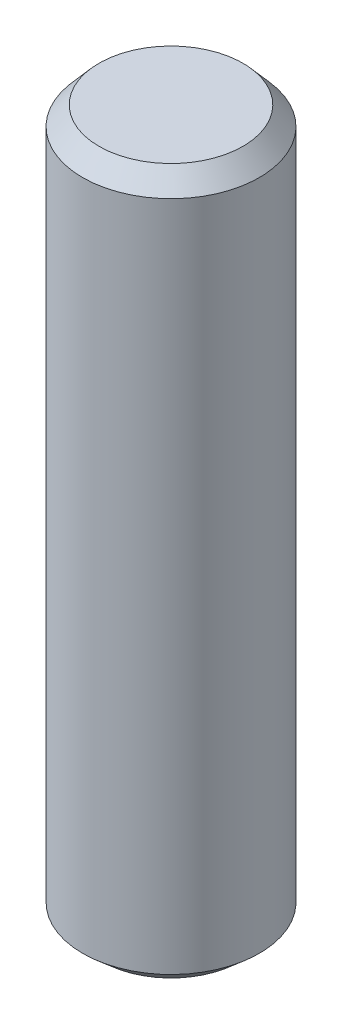
from build123d import *

# Parameters (mm, degrees)
SKETCH1_R             = 4.7625
BOSS_EXTRUDE1_DEPTH   = 19.05
CHAMFER1_SIZE         = 1.016
CHAMFER1_SIZE2        = 0.883195326
CHAMFER1_PART_2_SIZE  = 1.016
CHAMFER1_PART_2_SIZE2 = 0.883195326


with BuildPart() as part:
    # Sketch1 → Boss-Extrude1 (new body, symmetric)
    with BuildSketch(Plane(origin=(0, 0, 0), x_dir=(1, 0, 0), z_dir=(0, 1, 0))):
        Circle(SKETCH1_R)
    extrude(amount=BOSS_EXTRUDE1_DEPTH, both=True)

    # Chamfer1
    chamfer1_edges = [part.edges().sort_by_distance(p)[0] for p in [
        (-4.7625, -19.05, 0),
    ]]
    chamfer1_side = [part.faces().sort_by_distance(p)[0] for p in [
        (0, -19.05, 0),
    ]]
    chamfer(chamfer1_edges, length=CHAMFER1_SIZE, length2=CHAMFER1_SIZE2, reference=chamfer1_side[0])

    # Chamfer1 part 2
    chamfer1_part_2_edges = [part.edges().sort_by_distance(p)[0] for p in [
        (-4.7625, 19.05, 0),
    ]]
    chamfer1_part_2_side = [part.faces().sort_by_distance(p)[0] for p in [
        (-4.7625, 0, 0),
    ]]
    chamfer(chamfer1_part_2_edges, length=CHAMFER1_PART_2_SIZE, length2=CHAMFER1_PART_2_SIZE2, reference=chamfer1_part_2_side[0])


solid = part.part
